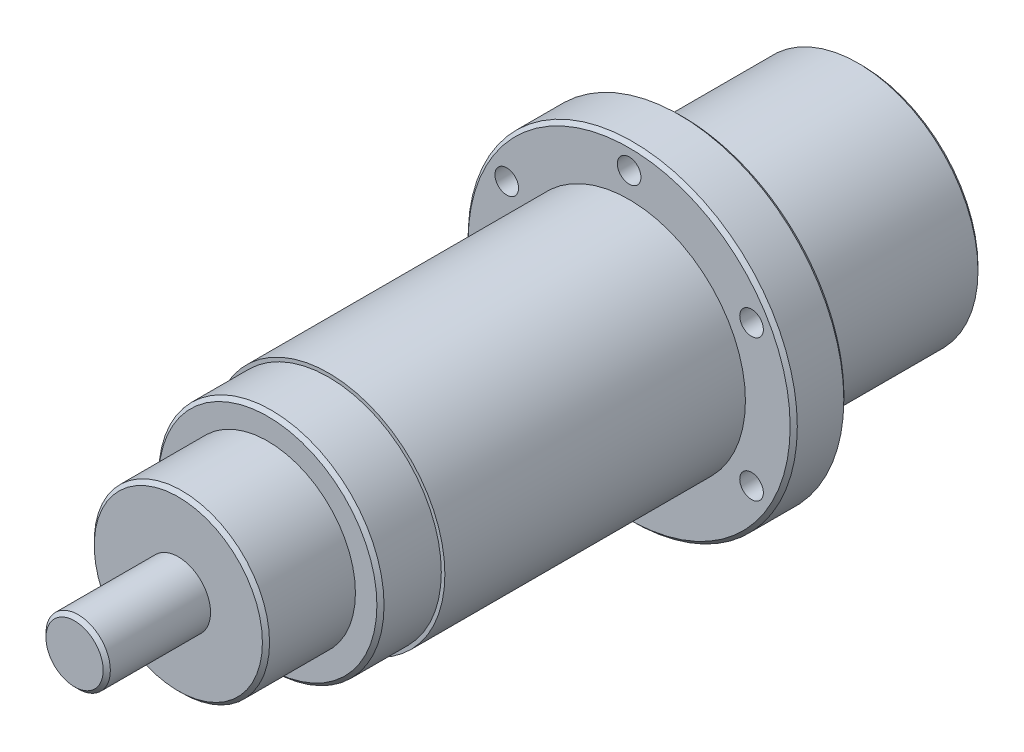
from build123d import *

# Parameters (mm, degrees)
SKETCH_1_R          = 33.5
EXTRUDE_1_DEPTH     = 50
SKETCH_2_R          = 46
EXTRUDE_2_DEPTH     = 15
SKETCH_3_R          = 32.5
EXTRUDE_3_DEPTH     = 84
SKETCH_4_R          = 31.5
EXTRUDE_4_DEPTH     = 17
SKETCH_5_R          = 24.5
EXTRUDE_5_DEPTH     = 25
SKETCH_6_R          = 9
EXTRUDE_6_DEPTH     = 29
SKETCH_7_R          = 15
CUT_EXTRUDE_1_DEPTH = 20
CHAMFER_1_SIZE      = 1
SKETCH_8_R          = 5.5
CUT_EXTRUDE_2_DEPTH = 7
SKETCH_9_R          = 3.3
CUT_EXTRUDE_3_DEPTH = 164


with BuildPart() as part:
    # 草图1 → 凸台-拉伸1 (new body)
    with BuildSketch(Plane.XY):
        Circle(SKETCH_1_R)
    extrude(amount=EXTRUDE_1_DEPTH)

    # 草图2 → 凸台-拉伸2 (add)
    with BuildSketch(Plane.XY.offset(50)):
        Circle(SKETCH_2_R)
    extrude(amount=EXTRUDE_2_DEPTH)

    # 草图3 → 凸台-拉伸3 (add)
    with BuildSketch(Plane.XY.offset(65)):
        Circle(SKETCH_3_R)
    extrude(amount=EXTRUDE_3_DEPTH)

    # 草图4 → 凸台-拉伸4 (add)
    with BuildSketch(Plane.XY.offset(149)):
        Circle(SKETCH_4_R)
    extrude(amount=EXTRUDE_4_DEPTH)

    # 草图5 → 凸台-拉伸5 (add)
    with BuildSketch(Plane.XY.offset(166)):
        Circle(SKETCH_5_R)
    extrude(amount=EXTRUDE_5_DEPTH)

    # 草图6 → 凸台-拉伸6 (add)
    with BuildSketch(Plane.XY.offset(191)):
        Circle(SKETCH_6_R)
    extrude(amount=EXTRUDE_6_DEPTH)

    # 草图7 → 切除-拉伸1 (cut)
    with BuildSketch(Plane(origin=(0, 0, 0), x_dir=(-1, 0, 0), z_dir=(0, 0, -1))):
        Circle(SKETCH_7_R)
    extrude(amount=-CUT_EXTRUDE_1_DEPTH, mode=Mode.SUBTRACT)

    # 倒角1
    chamfer_1_edges = [part.edges().sort_by_distance(p)[0] for p in [
        (-31.5, 0, 166),
        (-24.5, 0, 191),
        (-33.5, 0, 0),
        (-9, 0, 220),
        (-46, 0, 50),
        (-46, 0, 65),
    ]]
    chamfer(chamfer_1_edges, length=CHAMFER_1_SIZE)

    # 草图8 → 切除-拉伸2 (cut)
    with BuildSketch(Plane(origin=(0, 0, 50), x_dir=(-1, 0, 0), z_dir=(0, 0, -1))):
        with Locations((0, 39.5)):
            Circle(SKETCH_8_R)
        with Locations((34.208003449, 19.75)):
            Circle(SKETCH_8_R)
        with Locations((34.208003449, -19.75)):
            Circle(SKETCH_8_R)
        with Locations((0, -39.5)):
            Circle(SKETCH_8_R)
        with Locations((-34.208003449, -19.75)):
            Circle(SKETCH_8_R)
        with Locations((-34.208003449, 19.75)):
            Circle(SKETCH_8_R)
    extrude(amount=-CUT_EXTRUDE_2_DEPTH, mode=Mode.SUBTRACT)

    # 草图9 → 切除-拉伸3 (cut, through all)
    with BuildSketch(Plane(origin=(0, 0, 57), x_dir=(-1, 0, 0), z_dir=(0, 0, -1))):
        with Locations((0, 39.5)):
            Circle(SKETCH_9_R)
        with Locations((34.208003449, 19.75)):
            Circle(SKETCH_9_R)
        with Locations((34.208003449, -19.75)):
            Circle(SKETCH_9_R)
        with Locations((0, -39.5)):
            Circle(SKETCH_9_R)
        with Locations((-34.208003449, -19.75)):
            Circle(SKETCH_9_R)
        with Locations((-34.208003449, 19.75)):
            Circle(SKETCH_9_R)
    extrude(amount=-CUT_EXTRUDE_3_DEPTH, mode=Mode.SUBTRACT)


solid = part.part
